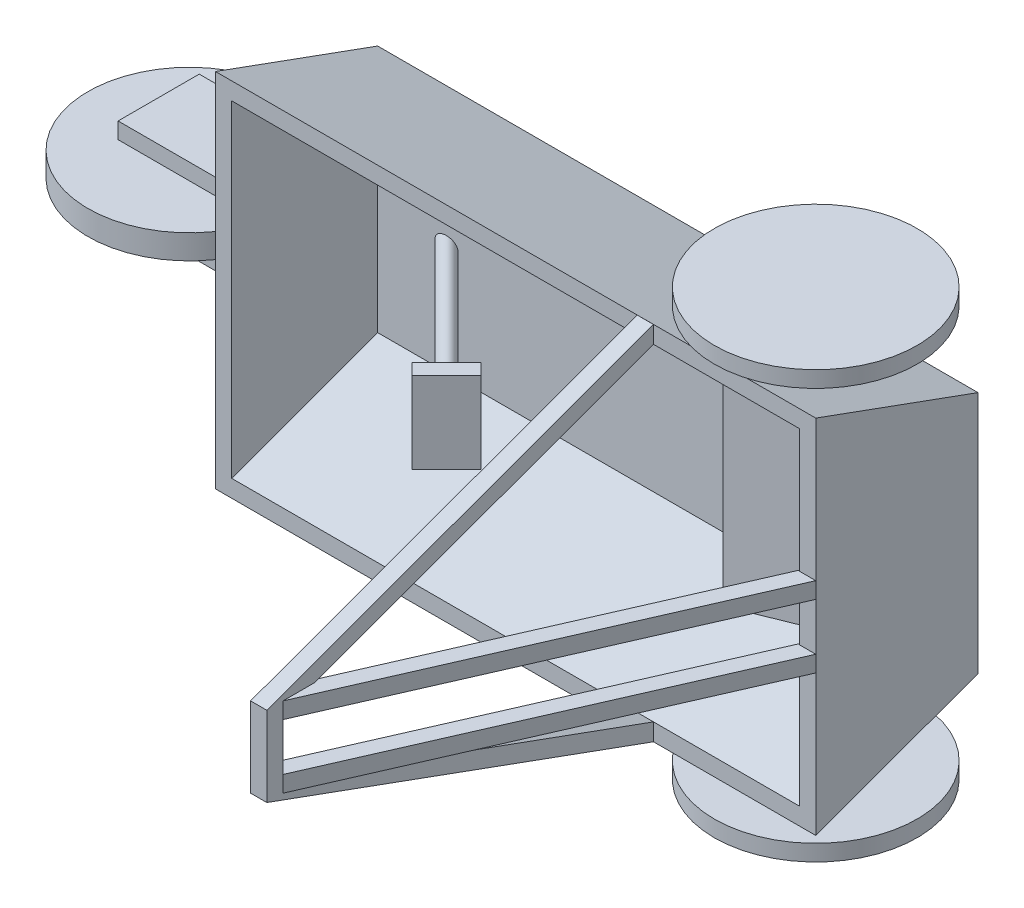
from build123d import *

# Parameters (mm, degrees)
SKETCH1_W                        = 88.9
SKETCH1_H                        = 38.1
BOSS_EXTRUDE1_DEPTH              = 2.54
BOSS_EXTRUDE2_DEPTH              = 88.9
BOSS_EXTRUDE3_DEPTH              = 2.54
SKETCH5_R                        = 2.54
BOSS_EXTRUDE4_DEPTH              = 2.54
BOSS_EXTRUDE4_DIRECTION_2_REACH  = 110.401
SKETCH6_R                        = 15.875
BOSS_EXTRUDE5_DEPTH              = 2.54
BOSS_EXTRUDE6_DEPTH              = 2.54
SKETCH8_W                        = 12.7
SKETCH8_H                        = 2.54
BOSS_EXTRUDE7_DEPTH              = 22.86
SKETCH9_R                        = 2.54
BOSS_EXTRUDE8_DEPTH              = 12.7
SKETCH11_R                       = 15.875
BOSS_EXTRUDE9_DEPTH              = 1.905
BOSS_EXTRUDE9_DEPTH_BACK         = 1.905
SKETCH13_W                       = 2.54
SKETCH13_H                       = 2.53363156
BOSS_EXTRUDE10_DEPTH             = 63.5
BOSS_EXTRUDE10_DIRECTION_2_REACH = 140.326
SKETCH16_W                       = 2.54
SKETCH16_H                       = 2.54
BOSS_EXTRUDE12_DEPTH             = 63.5
BOSS_EXTRUDE12_DIRECTION_2_REACH = 150.26
BOSS_EXTRUDE14_START             = -6.254388
SKETCH18_W                       = 2.54
SKETCH18_H                       = 2.54
BOSS_EXTRUDE14_DEPTH             = 12.514761
SKETCH19_W                       = 65.643872796
SKETCH19_H                       = 2.54
BOSS_EXTRUDE15_DEPTH             = 2.54
SKETCH20_W                       = 5.651471939
SKETCH20_H                       = 13.55717745
CUT_EXTRUDE1_DEPTH               = 2.54
SKETCH21_R                       = 1.27
BOSS_EXTRUDE16_DEPTH             = 39.116
SKETCH22_W                       = 9.722484857
SKETCH22_H                       = 17.213461762
CUT_EXTRUDE2_DEPTH               = 39.116
SKETCH23_W                       = 7.62
SKETCH23_H                       = 12.7
BOSS_EXTRUDE17_DEPTH             = 2.54
BOSS_EXTRUDE18_REACH             = 161.998
BOSS_EXTRUDE18_DIRECTION_2_REACH = 161.998


with BuildPart() as part:
    # Sketch1 → Boss-Extrude1 (new body)
    with BuildSketch(Plane.XY):
        with Locations((-44.45, 19.05)):
            Rectangle(SKETCH1_W, SKETCH1_H)
    extrude(amount=BOSS_EXTRUDE1_DEPTH)

    # Sketch2 → Boss-Extrude2 (add, through all)
    with BuildSketch(Plane.ZY.offset(88.9)):
        Polygon((0, 0), (25.4, -9.24484395), (25.4, -6.541832408), (2.54, 1.778527147), align=None)
        Polygon((0, 38.1), (25.4, 47.34484395), (25.4, 44.641832408), (2.54, 36.321472853), align=None)
    extrude(amount=-BOSS_EXTRUDE2_DEPTH)

    # Sketch3 → Boss-Extrude3 (add)
    with BuildSketch(Plane(origin=(0, 0, 0), x_dir=(0, 0, -1), z_dir=(1, 0, 0))):
        Polygon((-25.4, -9.24484395), (0, 0), (0, 38.1), (-25.4, 47.34484395), align=None)
    extrude(amount=BOSS_EXTRUDE3_DEPTH)

    # Sketch5 → Boss-Extrude4 (add)
    with BuildSketch(Plane(origin=(0, 47.34484395, 0), x_dir=(-1, 0, 0), z_dir=(0, 1, 0))):
        with Locations(Location((10.16, 12.7, 0), (0, 0, 90))):
            Circle(SKETCH5_R)
    boss_extrude4 = extrude(amount=BOSS_EXTRUDE4_DEPTH)

    # Sketch5 → Boss-Extrude4 direction 2 (add, up to next)
    with BuildSketch(Plane(origin=(0, 47.34484395, 0), x_dir=(-1, 0, 0), z_dir=(0, 1, 0)), mode=Mode.PRIVATE) as boss_extrude4_direction_2_sk1:
        with Locations(Location((10.16, 12.7, 0), (0, 0, 90))):
            Circle(SKETCH5_R)
    boss_extrude4_direction_2_tool1 = extrude(boss_extrude4_direction_2_sk1.sketch, amount=-BOSS_EXTRUDE4_DIRECTION_2_REACH, mode=Mode.PRIVATE) - part.part
    boss_extrude4_direction_2 = boss_extrude4_direction_2_tool1.solids().sort_by_distance((-10.16, 47.344844, 12.7))[0]
    add(boss_extrude4_direction_2)

    # Sketch6 → Boss-Extrude5 (add)
    with BuildSketch(Plane(origin=(0, 49.88484395, 0), x_dir=(1, 0, 0), z_dir=(0, 1, 0))):
        with Locations(Location((-10.16, -12.7, 0), (0, 0, 270))):
            Circle(SKETCH6_R)
    boss_extrude5 = extrude(amount=BOSS_EXTRUDE5_DEPTH)

    # Sketch7 → Boss-Extrude6 (add)
    with BuildSketch(Plane.ZY.offset(88.9)):
        Polygon((25.4, 47.34484395), (25.4, 19.05), (0, 19.05), (0, 38.1), align=None)
    boss_extrude6 = extrude(amount=BOSS_EXTRUDE6_DEPTH)

    # Mirror1: Boss-Extrude4, Boss-Extrude4 direction 2, Boss-Extrude5, Boss-Extrude6 across plane
    add(boss_extrude4.mirror(Plane(origin=(0, 19.05, 0), x_dir=(0, 0, 1), z_dir=(0, -1, 0))))
    add(boss_extrude4_direction_2.mirror(Plane(origin=(0, 19.05, 0), x_dir=(0, 0, 1), z_dir=(0, -1, 0))))
    add(boss_extrude5.mirror(Plane(origin=(0, 19.05, 0), x_dir=(0, 0, 1), z_dir=(0, -1, 0))))
    add(boss_extrude6.mirror(Plane(origin=(0, 19.05, 0), x_dir=(0, 0, 1), z_dir=(0, -1, 0))))

    # Sketch8 → Boss-Extrude7 (add)
    with BuildSketch(Plane.ZY.offset(91.44)):
        with Locations((11.43, 24.13)):
            Rectangle(SKETCH8_W, SKETCH8_H)
        with Locations((11.43, 13.97)):
            Rectangle(SKETCH8_W, SKETCH8_H)
    extrude(amount=BOSS_EXTRUDE7_DEPTH)

    # Sketch9 → Boss-Extrude8 (add)
    with BuildSketch(Plane(origin=(0, 12.7, 0), x_dir=(-1, 0, 0), z_dir=(0, -1, 0))):
        with Locations(Location((109.22, -11.699801303, 0), (0, 0, 90))):
            Circle(SKETCH9_R)
    extrude(amount=-BOSS_EXTRUDE8_DEPTH)

    # Sketch11 → Boss-Extrude9 (add, two sides)
    with BuildSketch(Plane(origin=(0, 19.05, 0), x_dir=(-1, 0, 0), z_dir=(0, -1, 0))) as boss_extrude9_sk:
        with Locations(Location((109.22, -11.699801303, 0), (0, 0, 180))):
            Circle(SKETCH11_R)
    extrude(amount=BOSS_EXTRUDE9_DEPTH)
    extrude(boss_extrude9_sk.sketch, amount=-BOSS_EXTRUDE9_DEPTH_BACK)


with BuildPart() as body_2:
    # Sketch13 → Boss-Extrude10 (new body)
    with BuildSketch(Plane(origin=(0, -2.941300262, 8.081156055), x_dir=(-1, 0, 0), z_dir=(0, 0.34202014332566333, -0.9396926207859104))):
        with Locations((24.13, 51.903727913)):
            Rectangle(SKETCH13_W, SKETCH13_H)
    extrude(amount=-BOSS_EXTRUDE10_DEPTH)


    # Sketch13 → Boss-Extrude10 direction 2 (add, up to next)
    with BuildSketch(Plane(origin=(0, -2.941300262, 8.081156055), x_dir=(-1, 0, 0), z_dir=(0, 0.34202014332566333, -0.9396926207859104)), mode=Mode.PRIVATE) as boss_extrude10_direction_2_sk1:
        with Locations((24.13, 51.903727913)):
            Rectangle(SKETCH13_W, SKETCH13_H)
    boss_extrude10_direction_2_tool1 = extrude(boss_extrude10_direction_2_sk1.sketch, amount=BOSS_EXTRUDE10_DIRECTION_2_REACH, mode=Mode.PRIVATE) - part.part
    add(boss_extrude10_direction_2_tool1.solids().sort_by_distance((-24.13, 45.83225, 25.833277))[0])


with BuildPart() as boss_extrude12_tool:
    # Sketch16 → Boss-Extrude12 (new body)
    with BuildSketch(Plane(origin=(0, 7.398153621, 20.326260019), x_dir=(-1, 0, 0), z_dir=(0, 0.34202014332566943, 0.9396926207859081))):
        with Locations((24.13, 16.104623281)):
            Rectangle(SKETCH16_W, SKETCH16_H)
    extrude(amount=BOSS_EXTRUDE12_DEPTH)


with BuildPart() as part_1:
    add(part.part)


with BuildPart() as part_2:
    # Boss-Extrude12: joined with boss_extrude12_tool
    add(part_1.part.fuse(boss_extrude12_tool.part, tol=0.00001))

    # Sketch16 → Boss-Extrude12 direction 2 (add, up to next)
    with BuildSketch(Plane(origin=(0, 7.398153621, 20.326260019), x_dir=(-1, 0, 0), z_dir=(0, 0.34202014332566943, 0.9396926207859081)), mode=Mode.PRIVATE) as boss_extrude12_direction_2_sk1:
        with Locations((24.13, 16.104623281)):
            Rectangle(SKETCH16_W, SKETCH16_H)
    boss_extrude12_direction_2_tool1 = extrude(boss_extrude12_direction_2_sk1.sketch, amount=-BOSS_EXTRUDE12_DIRECTION_2_REACH, mode=Mode.PRIVATE) - part_2.part
    add(boss_extrude12_direction_2_tool1.solids().sort_by_distance((-24.13, -7.735242, 25.834366))[0])


    add(body_2.part)  # Boss-Extrude14 merges body 2
    # Sketch18 → Boss-Extrude14 (add)
    with BuildSketch(Plane(origin=(0, 19.05, 0), x_dir=(-1, 0, 0), z_dir=(0, -1, 0)).offset(BOSS_EXTRUDE14_START)):
        with Locations((24.13, -84.669212584)):
            Rectangle(SKETCH18_W, SKETCH18_H)
    extrude(amount=BOSS_EXTRUDE14_DEPTH)

    # Sketch19 → Boss-Extrude15 (add)
    with BuildSketch(Plane(origin=(11.464782442, 0, 5.020852199), x_dir=(-0.40115477823907125, 0, 0.9160102859116602), z_dir=(-0.9160102859116602, 0, -0.40115477823907125))):
        with Locations((55.069664523, 14.059627436)):
            Rectangle(SKETCH19_W, SKETCH19_H)
        with Locations((55.069664523, 24.033595411)):
            Rectangle(SKETCH19_W, SKETCH19_H)
    extrude(amount=BOSS_EXTRUDE15_DEPTH)

    # Sketch20 → Cut-Extrude1 (cut)
    with BuildSketch(Plane.ZY.offset(25.4)):
        with Locations((83.113476615, 18.525006686)):
            Rectangle(SKETCH20_W, SKETCH20_H)
    extrude(amount=CUT_EXTRUDE1_DEPTH, mode=Mode.SUBTRACT)

    # Sketch21 → Boss-Extrude16 (add)
    with BuildSketch(Plane(origin=(-43.18, 0, -43.18), x_dir=(0, -1, 0), z_dir=(0.7071067811865488, 0, 0.7071067811865464))):
        with Locations(Location((-19.05, -57.037844072, 0), (0, 0, 270))):
            Circle(SKETCH21_R)
    extrude(amount=BOSS_EXTRUDE16_DEPTH)

    # Sketch22 → Cut-Extrude2 (cut)
    with BuildSketch(Plane(origin=(0, 0, 0), x_dir=(-1, 0, 0), z_dir=(0, 0, -1))):
        with Locations((79.946093386, 21.082088855)):
            Rectangle(SKETCH22_W, SKETCH22_H)
    extrude(amount=CUT_EXTRUDE2_DEPTH, mode=Mode.SUBTRACT)

    # Sketch23 → Boss-Extrude17 (add)
    with BuildSketch(Plane(origin=(-15.520811147, 0, -15.520811147), x_dir=(0.7071067811865465, 0, -0.7071067811865487), z_dir=(0.7071067811865487, 0, 0.7071067811865465))):
        with Locations((-57.037844072, 19.05)):
            Rectangle(SKETCH23_W, SKETCH23_H)
    extrude(amount=BOSS_EXTRUDE17_DEPTH)

    # Sketch25 → Boss-Extrude18 (add, up to next)
    with BuildSketch(Plane(origin=(0, 36.321472853, 0), x_dir=(-1, 0, 0), z_dir=(0, 1, 0)), mode=Mode.PRIVATE) as boss_extrude18_sk1:
        Polygon((0, 2.54), (27.469218062, 9.900354796), (29.441419185, 2.54), align=None)
    boss_extrude18_tool1 = extrude(boss_extrude18_sk1.sketch, amount=-BOSS_EXTRUDE18_REACH, mode=Mode.PRIVATE) - part_2.part
    add(boss_extrude18_tool1.solids().sort_by_distance((-18.970212, 36.321473, 4.993452))[0])

    # Sketch25 → Boss-Extrude18 direction 2 (add, up to next)
    with BuildSketch(Plane(origin=(0, 36.321472853, 0), x_dir=(-1, 0, 0), z_dir=(0, 1, 0)), mode=Mode.PRIVATE) as boss_extrude18_direction_2_sk1:
        Polygon((0, 2.54), (27.469218062, 9.900354796), (29.441419185, 2.54), align=None)
    boss_extrude18_direction_2_tool1 = extrude(boss_extrude18_direction_2_sk1.sketch, amount=BOSS_EXTRUDE18_DIRECTION_2_REACH, mode=Mode.PRIVATE) - part_2.part
    add(boss_extrude18_direction_2_tool1.solids().sort_by_distance((-18.970212, 36.321473, 4.993452))[0])


solid = part_2.part
